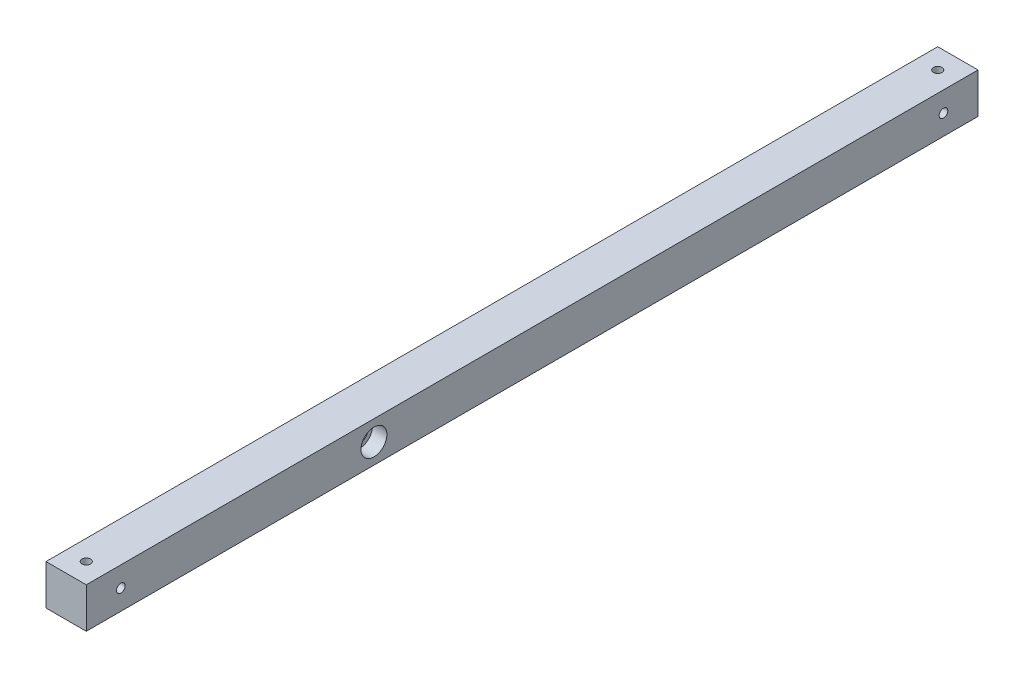
from build123d import *

# Parameters (mm, degrees)
IZIM1_W                     = 28
IZIM1_H                     = 28
Y_KSEKLIK_EKSTR_ZYON1_DEPTH = 620
IZIM3_R                     = 3
KES_EKSTR_ZYON2_DEPTH       = 29
IZIM4_R                     = 5
KES_EKSTR_ZYON3_DEPTH       = 7
IZIM5_R                     = 6
KES_EKSTR_ZYON4_DEPTH       = 29
IZIM6_R                     = 9
KES_EKSTR_ZYON5_DEPTH       = 10
IZIM7_R                     = 3
KES_EKSTR_ZYON6_DEPTH       = 29
IZIM8_R                     = 5
KES_EKSTR_ZYON7_DEPTH       = 7


with BuildPart() as part:
    # Çizim1 → Yükseklik-Ekstrüzyon1 (new body)
    with BuildSketch(Plane.XY):
        Rectangle(IZIM1_W, IZIM1_H)
    extrude(amount=Y_KSEKLIK_EKSTR_ZYON1_DEPTH)

    # Çizim3 → Kes-Ekstrüzyon2 (cut, through all)
    with BuildSketch(Plane.XZ.offset(14)):
        with Locations((0, 14)):
            Circle(IZIM3_R)
        with Locations((0, 606)):
            Circle(IZIM3_R)
    extrude(amount=-KES_EKSTR_ZYON2_DEPTH, mode=Mode.SUBTRACT)

    # Çizim4 → Kes-Ekstrüzyon3 (cut)
    with BuildSketch(Plane.XZ.offset(14)):
        with Locations((0, 14)):
            Circle(IZIM4_R)
        with Locations((0, 606)):
            Circle(IZIM4_R)
    extrude(amount=-KES_EKSTR_ZYON3_DEPTH, mode=Mode.SUBTRACT)

    # Çizim5 → Kes-Ekstrüzyon4 (cut, through all)
    with BuildSketch(Plane(origin=(14, 0, 0), x_dir=(0, 0, -1), z_dir=(1, 0, 0))):
        with Locations((-420, 0)):
            Circle(IZIM5_R)
    extrude(amount=-KES_EKSTR_ZYON4_DEPTH, mode=Mode.SUBTRACT)

    # Çizim6 → Kes-Ekstrüzyon5 (cut)
    with BuildSketch(Plane(origin=(14, 0, 0), x_dir=(0, 0, -1), z_dir=(1, 0, 0))):
        with Locations((-420, 0)):
            Circle(IZIM6_R)
    extrude(amount=-KES_EKSTR_ZYON5_DEPTH, mode=Mode.SUBTRACT)

    # Çizim7 → Kes-Ekstrüzyon6 (cut, through all)
    with BuildSketch(Plane.ZY.offset(14)):
        with Locations((24, 0)):
            Circle(IZIM7_R)
        with Locations((596, 0)):
            Circle(IZIM7_R)
    extrude(amount=-KES_EKSTR_ZYON6_DEPTH, mode=Mode.SUBTRACT)

    # Çizim8 → Kes-Ekstrüzyon7 (cut)
    with BuildSketch(Plane.ZY.offset(14)):
        with Locations((24, 0)):
            Circle(IZIM8_R)
        with Locations((596, 0)):
            Circle(IZIM8_R)
    extrude(amount=-KES_EKSTR_ZYON7_DEPTH, mode=Mode.SUBTRACT)


solid = part.part
